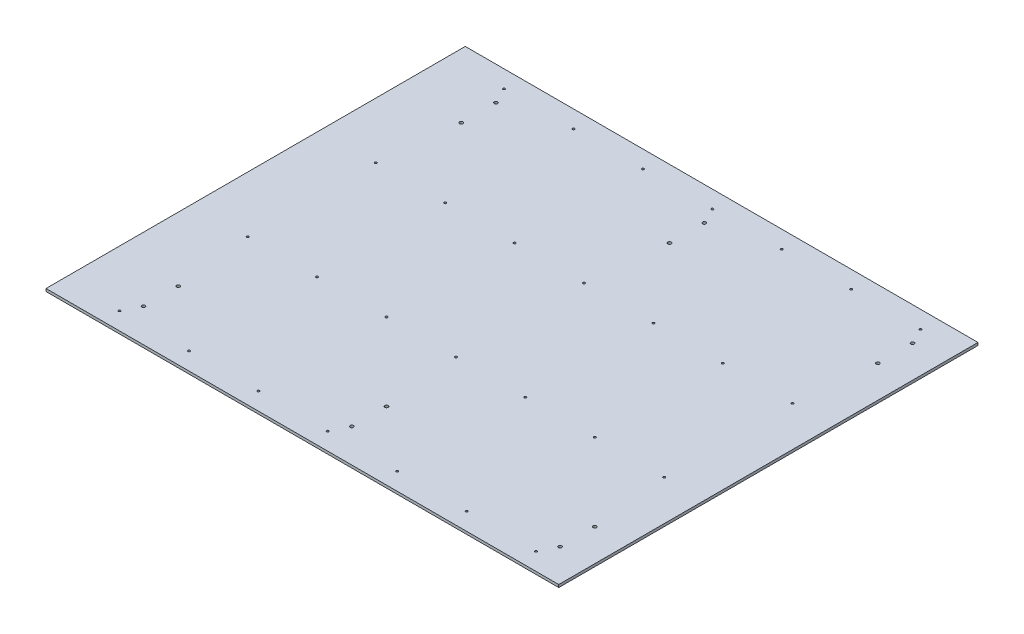
from build123d import *

# Parameters (mm, degrees)
SKETCH1_W                        = 1219.2
SKETCH1_H                        = 996.95
BOSS_EXTRUDE1_DEPTH              = 6.35
F_13_64_0_20313_DIAMETER_HOLE1_D = 5.159502
LPATTERN1_COUNT                  = 4
LPATTERN1_PITCH                  = 304.8
LPATTERN1_COUNT_DIR2             = 7
LPATTERN1_PITCH_DIR2             = 165.1
SKETCH4_R                        = 3.96875
CUT_EXTRUDE1_DEPTH               = 7.35
LPATTERN2_COUNT                  = 3
LPATTERN2_PITCH                  = 495.3
LPATTERN2_COPY_1_SKETCH_R        = 3.96875
LPATTERN2_COPY_1_DEPTH           = 7.35
LPATTERN2_COPY_2_SKETCH_R        = 3.96875
LPATTERN2_COPY_2_DEPTH           = 7.35


with BuildPart() as part:
    # Sketch1 → Boss-Extrude1 (new body)
    with BuildSketch(Plane(origin=(0, 0, 0), x_dir=(1, 0, 0), z_dir=(0, 1, 0))):
        Rectangle(SKETCH1_W, SKETCH1_H)
    extrude(amount=BOSS_EXTRUDE1_DEPTH)

    # 13/64 (0.20313) Diameter Hole1 (through all)
    with Locations(Plane(origin=(0, 6.35, 0), x_dir=(1, 0, 0), z_dir=(0, 1, 0))):
        with Locations((514.35, -457.2)):
            f_13_64_0_20313_diameter_hole1 = Hole(F_13_64_0_20313_DIAMETER_HOLE1_D / 2)

    # LPattern1: 13_64 _0.20313_ Diameter Hole1 4 × 7
    with Locations(*[(-j * LPATTERN1_PITCH_DIR2, 0, -i * LPATTERN1_PITCH) for i in range(LPATTERN1_COUNT) for j in range(LPATTERN1_COUNT_DIR2) if (i, j) != (0, 0)]):
        add(f_13_64_0_20313_diameter_hole1, mode=Mode.SUBTRACT)

    # Sketch4 → Cut-Extrude1 (cut, through all)
    with BuildSketch(Plane(origin=(0, 6.35, 0), x_dir=(1, 0, 0), z_dir=(0, 1, 0))):
        with Locations((533.4, 419.1)):
            Circle(SKETCH4_R)
        with Locations((533.4, 336.55)):
            Circle(SKETCH4_R)
    cut_extrude1 = extrude(amount=-CUT_EXTRUDE1_DEPTH, mode=Mode.SUBTRACT)

    # Mirror1: Cut-Extrude1 across plane
    add(cut_extrude1.mirror(Plane.XY), mode=Mode.SUBTRACT)

    # LPattern2: Cut-Extrude1 ×3
    with Locations(*[(-i * LPATTERN2_PITCH, 0, 0) for i in range(1, LPATTERN2_COUNT)]):
        add(cut_extrude1, mode=Mode.SUBTRACT)

    # LPattern2 copy 1 sketch → LPattern2 copy 1 (cut, through all)
    with BuildSketch(Plane(origin=(-495.3, 6.35, 0), x_dir=(1, 0, 0), z_dir=(0, 1, 0))):
        with Locations((533.4, -419.1)):
            Circle(LPATTERN2_COPY_1_SKETCH_R)
        with Locations((533.4, -336.55)):
            Circle(LPATTERN2_COPY_1_SKETCH_R)
    extrude(amount=-LPATTERN2_COPY_1_DEPTH, mode=Mode.SUBTRACT)

    # LPattern2 copy 2 sketch → LPattern2 copy 2 (cut, through all)
    with BuildSketch(Plane(origin=(-990.6, 6.35, 0), x_dir=(1, 0, 0), z_dir=(0, 1, 0))):
        with Locations((533.4, -419.1)):
            Circle(LPATTERN2_COPY_2_SKETCH_R)
        with Locations((533.4, -336.55)):
            Circle(LPATTERN2_COPY_2_SKETCH_R)
    extrude(amount=-LPATTERN2_COPY_2_DEPTH, mode=Mode.SUBTRACT)


solid = part.part
